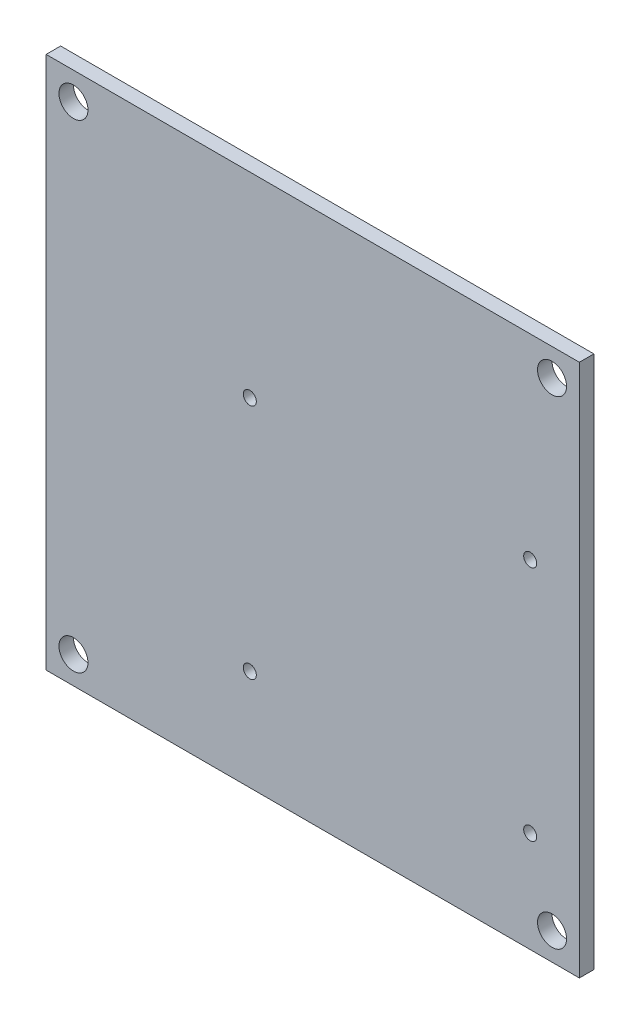
from build123d import *

# Parameters (mm, degrees)
CROQUIS1_W              = 110.308657865
CROQUIS1_H              = 110.308657865
CROQUIS1_R              = 3
SALIENTE_EXTRUIR1_DEPTH = 3
CROQUIS3_R              = 1.35
CORTAR_EXTRUIR1_DEPTH   = 4


with BuildPart() as part:
    # Croquis1 → Saliente-Extruir1 (new body)
    with BuildSketch(Plane.XY.offset(1001.5)):
        with Locations((-24.891577249, 6.700344828)):
            Rectangle(CROQUIS1_W, CROQUIS1_H)
        with Locations((-74.389051931, 56.197819511)):
            Circle(CROQUIS1_R, mode=Mode.SUBTRACT)
        with Locations((24.605897435, -42.797129855)):
            Circle(CROQUIS1_R, mode=Mode.SUBTRACT)
        with Locations((-74.389051931, -42.797129855)):
            Circle(CROQUIS1_R, mode=Mode.SUBTRACT)
        with Locations((24.605897435, 56.197819511)):
            Circle(CROQUIS1_R, mode=Mode.SUBTRACT)
    extrude(amount=-SALIENTE_EXTRUIR1_DEPTH)

    # Croquis3 → Cortar-Extruir1 (cut, through all)
    with BuildSketch(Plane(origin=(0, 0, 998.5), x_dir=(-1, 0, 0), z_dir=(0, 0, -1))):
        with Locations((37.910718234, 21.399287334)):
            Circle(CROQUIS3_R)
        with Locations((37.910718234, -27.600712666)):
            Circle(CROQUIS3_R)
        with Locations((-20.089281766, -27.600712666)):
            Circle(CROQUIS3_R)
        with Locations((-20.089281766, 21.399287334)):
            Circle(CROQUIS3_R)
    extrude(amount=-CORTAR_EXTRUIR1_DEPTH, mode=Mode.SUBTRACT)


solid = part.part
